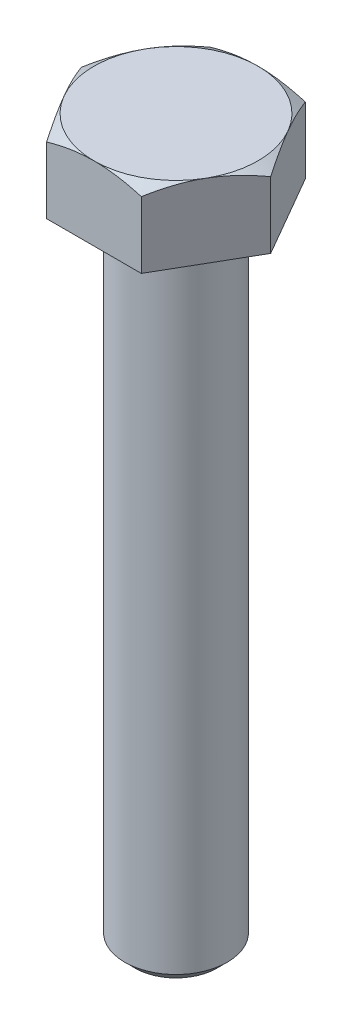
from build123d import *

# Parameters (mm, degrees)
BOSS_EXTRUDE1_DEPTH = 3.6
SKETCH3_R           = 2.5
BOSS_EXTRUDE2_DEPTH = 31.5
CHAMFER1_SIZE       = 0.5
FILLET1_R           = 0.4


with BuildPart() as part:
    # Sketch1 → Boss-Extrude1 (new body)
    with BuildSketch(Plane(origin=(0, 0, 0), x_dir=(1, 0, 0), z_dir=(0, 1, 0))):
        Polygon((-2.309401077, -4), (2.309401077, -4), (4.618802154, 0), (2.309401077, 4), (-2.309401077, 4), (-4.618802154, 0), align=None)
    extrude(amount=BOSS_EXTRUDE1_DEPTH)

    # Sketch2 → Cut-Revolve1 (revolve, cut)
    with BuildSketch(Plane(origin=(0, 0, 0), x_dir=(0, 0, -1), z_dir=(1, 0, 0))):
        Polygon((8.326224825, 1.102252933), (4, 3.6), (8.326224825, 3.6), align=None)
    revolve(axis=Axis((0, 0, 0), (0, 1, 0)), mode=Mode.SUBTRACT)

    # Sketch3 → Boss-Extrude2 (add)
    with BuildSketch(Plane.XZ):
        Circle(SKETCH3_R)
    extrude(amount=BOSS_EXTRUDE2_DEPTH)

    # Chamfer1
    chamfer1_edges = [part.edges().sort_by_distance(p)[0] for p in [
        (-2.5, -31.5, 0),
    ]]
    chamfer(chamfer1_edges, length=CHAMFER1_SIZE)

    # Fillet1
    fillet1_edges = [part.edges().sort_by_distance(p)[0] for p in [
        (-2.5, 0, 0),
    ]]
    fillet(fillet1_edges, radius=FILLET1_R)


solid = part.part
